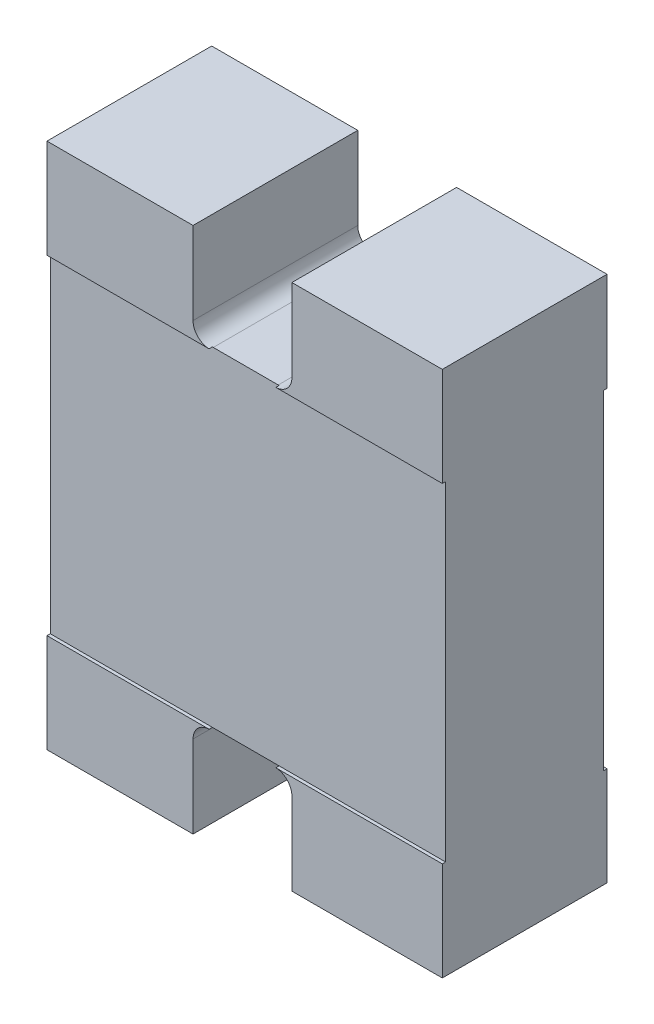
from build123d import *

# Parameters (mm, degrees)
SKETCH1_W           = 1.2
SKETCH1_H           = 1.6
BOSS_EXTRUDE1_DEPTH = 0.5
CUT_EXTRUDE1_DEPTH  = 1.5
SKETCH3_W           = 1.2
SKETCH3_H           = 1
CUT_EXTRUDE2_DEPTH  = 0.01


with BuildPart() as part:
    # Sketch1 → Boss-Extrude1 (new body)
    with BuildSketch(Plane.XY):
        Rectangle(SKETCH1_W, SKETCH1_H)
    extrude(amount=BOSS_EXTRUDE1_DEPTH)

    # Sketch2 → Cut-Extrude1 (cut, through all)
    with BuildSketch(Plane(origin=(0, 0, 0), x_dir=(-1, 0, 0), z_dir=(0, 0, -1))):
        with BuildLine():
            Line((0.156619149, 0.8), (0.156619149, 0.549979938))
            ThreePointArc((0.156619149, 0.549979938), (0.14148119, 0.514138446), (0.105233781, 0.5))
            Line((0.105233781, 0.5), (-0.091995219, 0.5))
            ThreePointArc((-0.091995219, 0.5), (-0.128242628, 0.514138446), (-0.143380586, 0.549979938))
            Line((-0.143380586, 0.549979938), (-0.143380851, 0.8))
            Line((-0.143380851, 0.8), (0.156619149, 0.8))
        make_face()
    cut_extrude1 = extrude(amount=-CUT_EXTRUDE1_DEPTH, mode=Mode.SUBTRACT)

    # Sketch3 → Cut-Extrude2 (cut)
    with BuildSketch(Plane(origin=(0, 0, 0), x_dir=(-1, 0, 0), z_dir=(0, 0, -1))):
        Rectangle(SKETCH3_W, SKETCH3_H)
    cut_extrude2 = extrude(amount=-CUT_EXTRUDE2_DEPTH, mode=Mode.SUBTRACT)

    # Mirror0: Cut-Extrude1 across plane
    add(cut_extrude1.mirror(Plane.ZX), mode=Mode.SUBTRACT)

    # Mirror1: Cut-Extrude2 across plane
    add(cut_extrude2.mirror(Plane(origin=(0, 0, 0.25), x_dir=(1, 0, 0), z_dir=(0, 0, -1))), mode=Mode.SUBTRACT)


solid = part.part
